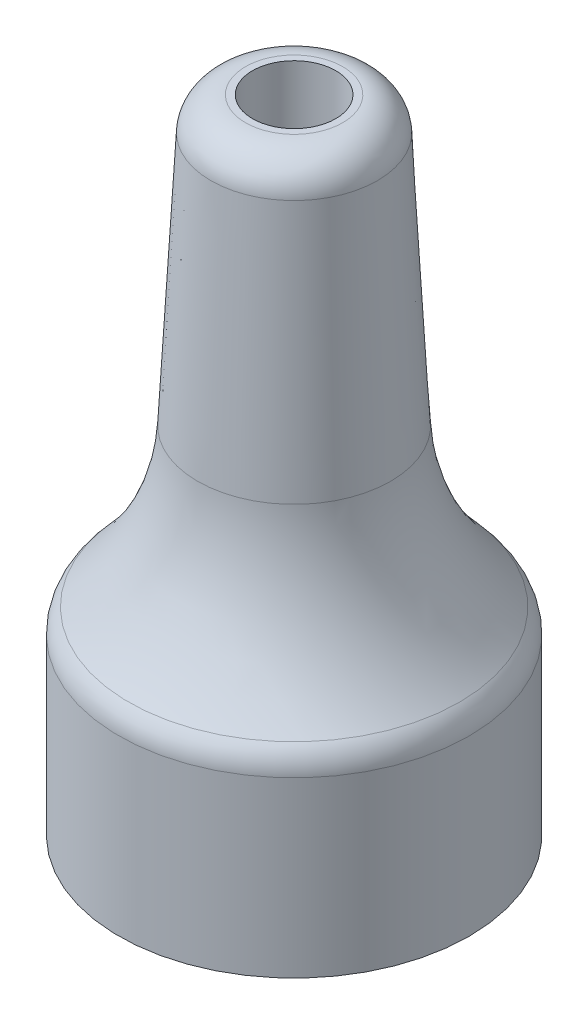
from build123d import *

# Parameters (mm, degrees)
FILLET1_R = 1
FILLET2_R = 7


with BuildPart() as part:
    # Sketch1 → Revolve1 (revolve)
    with BuildSketch(Plane.XY):
        Polygon((-2.35, 12.482869184), (-3.004199453, 0), (-5.05, 0), (-5.05, -6), (-3.95, -6), (-3.95, -1), (-1.2, -1), (-1.2, 12.482869184), align=None)
    revolve(axis=Axis((0, -1000, 0), (0, 1, 0)))

    # Fillet1
    fillet1_edges = [part.edges().sort_by_distance(p)[0] for p in [
        (2.35, 12.482869184, 0),
        (5.05, 0, 0),
    ]]
    fillet(fillet1_edges, radius=FILLET1_R)

    # Fillet2
    fillet2_edges = [part.edges().sort_by_distance(p)[0] for p in [
        (3.004199453, 0, 0),
    ]]
    fillet(fillet2_edges, radius=FILLET2_R)


solid = part.part
